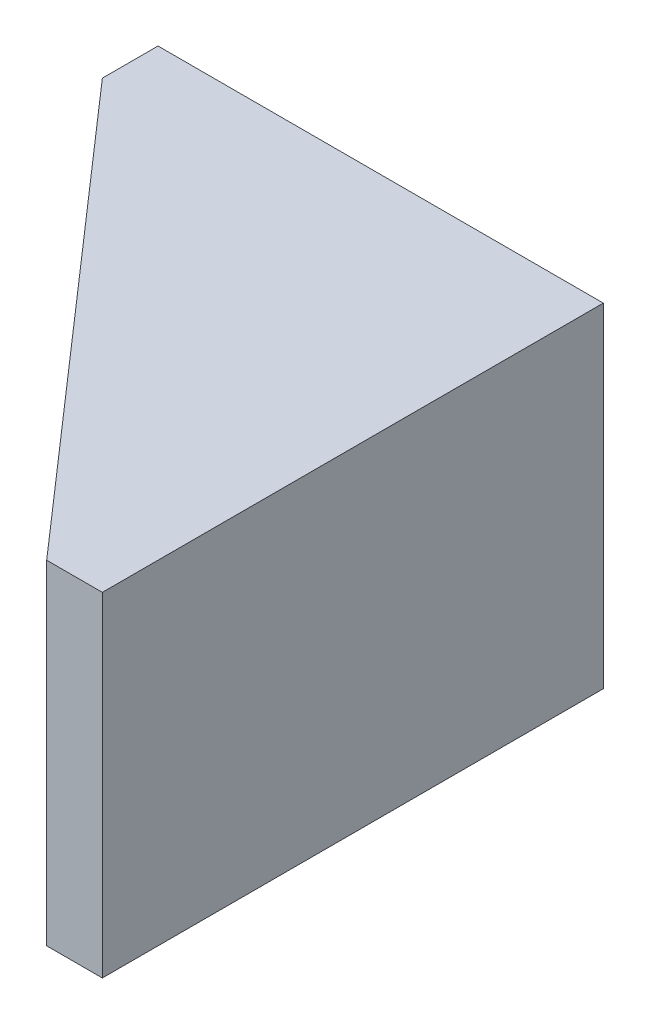
from build123d import *

# Parameters (mm, degrees)
SKETCH1_W           = 25.4
SKETCH1_H           = 19.05
SKETCH1_R           = 2
BOSS_EXTRUDE1_DEPTH = 3.175
SKETCH2_W           = 3.175
SKETCH2_H           = 19.05
BOSS_EXTRUDE2_DEPTH = 25.4
RIB1_REACH          = 44.715
SKETCH3_WALL_W      = 121.181225654
SKETCH3_WALL_H      = 3.175


with BuildPart() as part:
    # Sketch1 → Boss-Extrude1 (new body)
    with BuildSketch(Plane.XY):
        with Locations((-12.7, 0)):
            Rectangle(SKETCH1_W, SKETCH1_H)
        with Locations((-9.525, 0)):
            Circle(SKETCH1_R, mode=Mode.SUBTRACT)
        with Locations((-19.05, 0)):
            Circle(SKETCH1_R, mode=Mode.SUBTRACT)
    extrude(amount=BOSS_EXTRUDE1_DEPTH)

    # Sketch2 → Boss-Extrude2 (add)
    with BuildSketch(Plane.XY.offset(3.175)):
        with Locations((-1.5875, 0)):
            Rectangle(SKETCH2_W, SKETCH2_H)
    extrude(amount=BOSS_EXTRUDE2_DEPTH)

    # Sketch3 wall → Rib1 (add, up to next)
    with BuildSketch(Plane(origin=(-14.2875, 9.525, 15.875), x_dir=(0.658504607869, 0, 0.752576694707), z_dir=(0.752576694707, 0, -0.658504607869)), mode=Mode.PRIVATE) as rib1_sk1:
        with Locations((0, 1.5875)):
            Rectangle(SKETCH3_WALL_W, SKETCH3_WALL_H)
    rib1_tool1 = extrude(rib1_sk1.sketch, amount=RIB1_REACH, mode=Mode.PRIVATE) - part.part
    rib1 = rib1_tool1.solids().sort_by_distance((-14.2875, 9.525, 15.875))[0]
    add(rib1)

    # Mirror1: Rib1 across plane
    add(rib1.mirror(Plane.ZX))


solid = part.part
